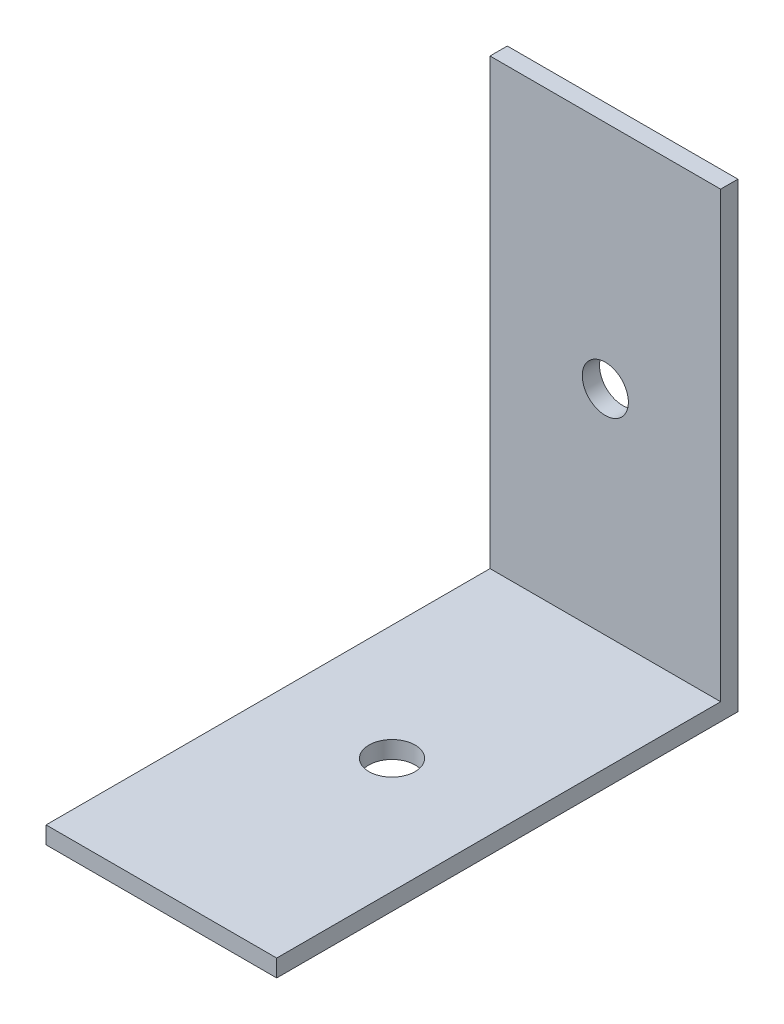
from build123d import *

# Parameters (mm, degrees)
SKETCH1_W           = 20
SKETCH1_H           = 40
SKETCH1_R           = 2
BOSS_EXTRUDE1_DEPTH = 1.5
SKETCH2_W           = 20
SKETCH2_H           = 1.5
BOSS_EXTRUDE2_DEPTH = 38.5
SKETCH3_R           = 2
CUT_EXTRUDE1_DEPTH  = 1.5


with BuildPart() as part:
    # Sketch1 → Boss-Extrude1 (new body)
    with BuildSketch(Plane(origin=(0, 0, 0), x_dir=(1, 0, 0), z_dir=(0, 1, 0))):
        Rectangle(SKETCH1_W, SKETCH1_H)
        Circle(SKETCH1_R, mode=Mode.SUBTRACT)
    extrude(amount=BOSS_EXTRUDE1_DEPTH)

    # Sketch2 → Boss-Extrude2 (add)
    with BuildSketch(Plane(origin=(0, 1.5, 0), x_dir=(1, 0, 0), z_dir=(0, 1, 0))):
        with Locations((0, 19.25)):
            Rectangle(SKETCH2_W, SKETCH2_H)
    extrude(amount=BOSS_EXTRUDE2_DEPTH)

    # Sketch3 → Cut-Extrude1 (cut)
    with BuildSketch(Plane(origin=(0, 0, -20), x_dir=(-1, 0, 0), z_dir=(0, 0, -1))):
        with Locations((0, 20)):
            Circle(SKETCH3_R)
    extrude(amount=-CUT_EXTRUDE1_DEPTH, mode=Mode.SUBTRACT)


solid = part.part
